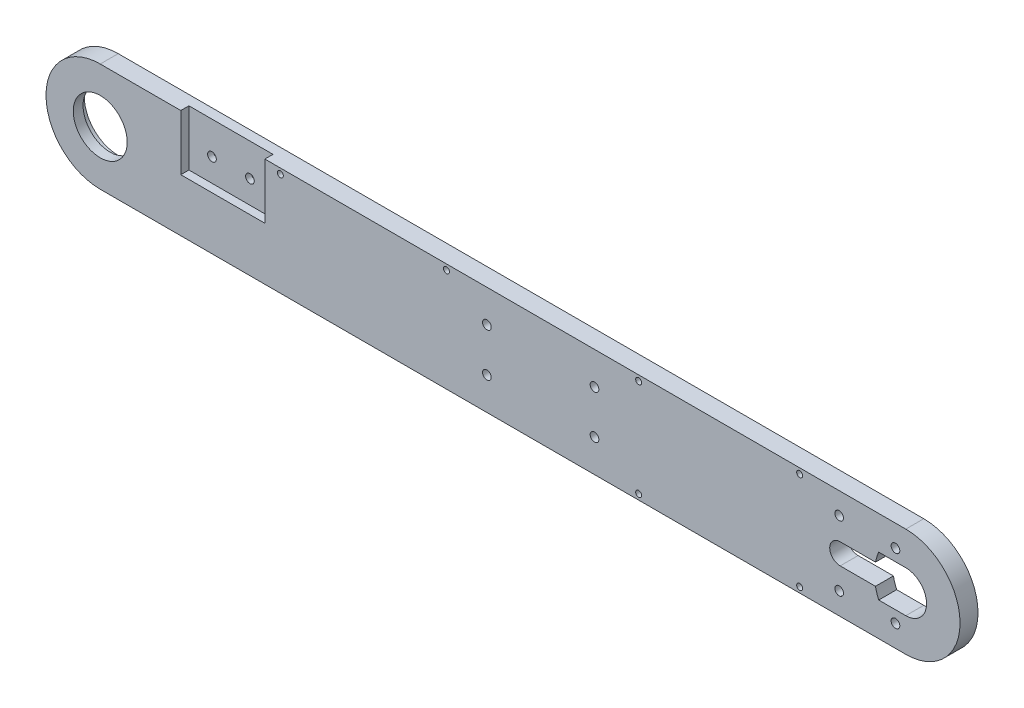
from build123d import *

# Parameters (mm, degrees)
BOSS_EXTRUDE1_DEPTH = 6.62
CUT_EXTRUDE1_REACH  = 8.62
CUT_EXTRUDE2_REACH  = 8.62
SKETCH3_R           = 1.6
SKETCH4_R           = 2.75
CUT_EXTRUDE3_DEPTH  = 3.2
SKETCH6_R           = 9.95
CUT_EXTRUDE4_DEPTH  = 10
SKETCH7_R           = 12.5
CUT_EXTRUDE5_DEPTH  = 3
CUT_EXTRUDE9_REACH  = 8.62
SKETCH10_R          = 1.600000003
SKETCH11_R          = 2.750000001
CUT_EXTRUDE10_DEPTH = 3
SKETCH12_W          = 31
SKETCH12_H          = 20.5
CUT_EXTRUDE11_DEPTH = 3
CUT_EXTRUDE12_REACH = 8.62
SKETCH13_R          = 1.6
SKETCH14_R          = 2.75
CUT_EXTRUDE13_DEPTH = 1.5
CUT_EXTRUDE14_REACH = 8.62
SKETCH15_R          = 1.1


with BuildPart() as part:
    # Sketch1 → Boss-Extrude1 (new body)
    with BuildSketch(Plane.XY):
        with BuildLine():
            Line((-53.15, -20.367507575), (-350.15, -20.367507575))
            ThreePointArc((-350.15, -20.367507575), (-370.15, -0.367507575), (-350.15, 19.632492425))
            Line((-350.15, 19.632492425), (-53.15, 19.632492425))
            ThreePointArc((-53.15, 19.632492425), (-33.15, -0.367507575), (-53.15, -20.367507575))
        make_face()
    extrude(amount=BOSS_EXTRUDE1_DEPTH)

    # Sketch2 → Cut-Extrude1 (cut, up to next)
    with BuildSketch(Plane(origin=(0, 0, 0), x_dir=(-1, 0, 0), z_dir=(0, 0, -1)), mode=Mode.PRIVATE) as cut_extrude1_sk1:
        with BuildLine():
            Line((53.15, 7.282492425), (63.133045479, 7.282492425))
            ThreePointArc((63.133045479, 7.282492425), (63.830991164, 5.41363036), (64.33147081, 3.482492425))
            Line((64.33147081, 3.482492425), (77.35, 3.482492425))
            ThreePointArc((77.35, 3.482492425), (81.2, -0.367507575), (77.35, -4.217507575))
            Line((77.35, -4.217507575), (64.33147081, -4.217507575))
            ThreePointArc((64.33147081, -4.217507575), (63.830991164, -6.14864551), (63.133045479, -8.017507575))
            Line((63.133045479, -8.017507575), (53.15, -8.017507575))
            ThreePointArc((53.15, -8.017507575), (45.5, -0.367507575), (53.15, 7.282492425))
        make_face()
    cut_extrude1_tool1 = extrude(cut_extrude1_sk1.sketch, amount=-CUT_EXTRUDE1_REACH, mode=Mode.PRIVATE) & part.part
    add(cut_extrude1_tool1.solids().sort_by_distance((-60.965388, -0.367508, 0))[0], mode=Mode.SUBTRACT)

    # Sketch3 → Cut-Extrude2 (cut, up to next)
    with BuildSketch(Plane(origin=(0, 0, 0), x_dir=(-1, 0, 0), z_dir=(0, 0, -1)), mode=Mode.PRIVATE) as cut_extrude2_sk1:
        with Locations((77.715530374, -12.367507575)):
            Circle(SKETCH3_R)
    cut_extrude2_tool1 = extrude(cut_extrude2_sk1.sketch, amount=-CUT_EXTRUDE2_REACH, mode=Mode.PRIVATE) & part.part
    add(cut_extrude2_tool1.solids().sort_by_distance((-77.71553, -12.367508, 0))[0], mode=Mode.SUBTRACT)
    # Sketch3 → Cut-Extrude2 (cut, up to next)
    with BuildSketch(Plane(origin=(0, 0, 0), x_dir=(-1, 0, 0), z_dir=(0, 0, -1)), mode=Mode.PRIVATE) as cut_extrude2_sk2:
        with Locations((77.715530374, 11.632492425)):
            Circle(SKETCH3_R)
    cut_extrude2_tool2 = extrude(cut_extrude2_sk2.sketch, amount=-CUT_EXTRUDE2_REACH, mode=Mode.PRIVATE) & part.part
    add(cut_extrude2_tool2.solids().sort_by_distance((-77.71553, 11.632492, 0))[0], mode=Mode.SUBTRACT)
    # Sketch3 → Cut-Extrude2 (cut, up to next)
    with BuildSketch(Plane(origin=(0, 0, 0), x_dir=(-1, 0, 0), z_dir=(0, 0, -1)), mode=Mode.PRIVATE) as cut_extrude2_sk3:
        with Locations((56.965530374, 11.632492425)):
            Circle(SKETCH3_R)
    cut_extrude2_tool3 = extrude(cut_extrude2_sk3.sketch, amount=-CUT_EXTRUDE2_REACH, mode=Mode.PRIVATE) & part.part
    add(cut_extrude2_tool3.solids().sort_by_distance((-56.96553, 11.632492, 0))[0], mode=Mode.SUBTRACT)
    # Sketch3 → Cut-Extrude2 (cut, up to next)
    with BuildSketch(Plane(origin=(0, 0, 0), x_dir=(-1, 0, 0), z_dir=(0, 0, -1)), mode=Mode.PRIVATE) as cut_extrude2_sk4:
        with Locations((56.965530374, -12.367507575)):
            Circle(SKETCH3_R)
    cut_extrude2_tool4 = extrude(cut_extrude2_sk4.sketch, amount=-CUT_EXTRUDE2_REACH, mode=Mode.PRIVATE) & part.part
    add(cut_extrude2_tool4.solids().sort_by_distance((-56.96553, -12.367508, 0))[0], mode=Mode.SUBTRACT)

    # Sketch4 → Cut-Extrude3 (cut)
    with BuildSketch(Plane(origin=(0, 0, 0), x_dir=(-1, 0, 0), z_dir=(0, 0, -1))):
        with Locations((56.965530374, 11.632492425)):
            Circle(SKETCH4_R)
        with Locations((77.715530374, 11.632492425)):
            Circle(SKETCH4_R)
        with Locations((77.715530374, -12.367507575)):
            Circle(SKETCH4_R)
        with Locations((56.965530374, -12.367507575)):
            Circle(SKETCH4_R)
    extrude(amount=-CUT_EXTRUDE3_DEPTH, mode=Mode.SUBTRACT)

    # Sketch6 → Cut-Extrude4 (cut)
    with BuildSketch(Plane.XY.offset(6.62)):
        with Locations((-350.15, -0.367507575)):
            Circle(SKETCH6_R)
    extrude(amount=-CUT_EXTRUDE4_DEPTH, mode=Mode.SUBTRACT)

    # Sketch7 → Cut-Extrude5 (cut)
    with BuildSketch(Plane(origin=(0, 0, 0), x_dir=(-1, 0, 0), z_dir=(0, 0, -1))):
        with Locations((350.15, -0.367507575)):
            Circle(SKETCH7_R)
    extrude(amount=-CUT_EXTRUDE5_DEPTH, mode=Mode.SUBTRACT)

    # Sketch10 → Cut-Extrude9 (cut, up to next)
    with BuildSketch(Plane.XY.offset(6.62), mode=Mode.PRIVATE) as cut_extrude9_sk1:
        with Locations((-207.590530375, -8.367507581)):
            Circle(SKETCH10_R)
    cut_extrude9_tool1 = extrude(cut_extrude9_sk1.sketch, amount=-CUT_EXTRUDE9_REACH, mode=Mode.PRIVATE) & part.part
    add(cut_extrude9_tool1.solids().sort_by_distance((-207.59053, -8.367508, 6.62))[0], mode=Mode.SUBTRACT)
    # Sketch10 → Cut-Extrude9 (cut, up to next)
    with BuildSketch(Plane.XY.offset(6.62), mode=Mode.PRIVATE) as cut_extrude9_sk2:
        with Locations((-207.590530375, 7.632492419)):
            Circle(SKETCH10_R)
    cut_extrude9_tool2 = extrude(cut_extrude9_sk2.sketch, amount=-CUT_EXTRUDE9_REACH, mode=Mode.PRIVATE) & part.part
    add(cut_extrude9_tool2.solids().sort_by_distance((-207.59053, 7.632492, 6.62))[0], mode=Mode.SUBTRACT)
    # Sketch10 → Cut-Extrude9 (cut, up to next)
    with BuildSketch(Plane.XY.offset(6.62), mode=Mode.PRIVATE) as cut_extrude9_sk3:
        with Locations((-167.917908126, -8.367507581)):
            Circle(SKETCH10_R)
    cut_extrude9_tool3 = extrude(cut_extrude9_sk3.sketch, amount=-CUT_EXTRUDE9_REACH, mode=Mode.PRIVATE) & part.part
    add(cut_extrude9_tool3.solids().sort_by_distance((-167.917908, -8.367508, 6.62))[0], mode=Mode.SUBTRACT)
    # Sketch10 → Cut-Extrude9 (cut, up to next)
    with BuildSketch(Plane.XY.offset(6.62), mode=Mode.PRIVATE) as cut_extrude9_sk4:
        with Locations((-167.917908126, 7.632492419)):
            Circle(SKETCH10_R)
    cut_extrude9_tool4 = extrude(cut_extrude9_sk4.sketch, amount=-CUT_EXTRUDE9_REACH, mode=Mode.PRIVATE) & part.part
    add(cut_extrude9_tool4.solids().sort_by_distance((-167.917908, 7.632492, 6.62))[0], mode=Mode.SUBTRACT)

    # Sketch11 → Cut-Extrude10 (cut)
    with BuildSketch(Plane(origin=(0, 0, 0), x_dir=(-1, 0, 0), z_dir=(0, 0, -1))):
        with Locations((207.590530375, 7.632492419)):
            Circle(SKETCH11_R)
        with Locations((207.590530375, -8.367507581)):
            Circle(SKETCH11_R)
        with Locations((167.917908126, 7.632492419)):
            Circle(SKETCH11_R)
        with Locations((167.917908126, -8.367507581)):
            Circle(SKETCH11_R)
    extrude(amount=-CUT_EXTRUDE10_DEPTH, mode=Mode.SUBTRACT)

    # Sketch12 → Cut-Extrude11 (cut)
    with BuildSketch(Plane.XY.offset(6.62)):
        with Locations((-304.957095584, 9.382492425)):
            Rectangle(SKETCH12_W, SKETCH12_H)
    extrude(amount=-CUT_EXTRUDE11_DEPTH, mode=Mode.SUBTRACT)

    # Sketch13 → Cut-Extrude12 (cut, up to next)
    with BuildSketch(Plane.XY.offset(6.62), mode=Mode.PRIVATE) as cut_extrude12_sk1:
        with Locations((-311.957095584, 7.632492425)):
            Circle(SKETCH13_R)
    cut_extrude12_tool1 = extrude(cut_extrude12_sk1.sketch, amount=-CUT_EXTRUDE12_REACH, mode=Mode.PRIVATE) & part.part
    add(cut_extrude12_tool1.solids().sort_by_distance((-311.957096, 7.632492, 6.62))[0], mode=Mode.SUBTRACT)
    # Sketch13 → Cut-Extrude12 (cut, up to next)
    with BuildSketch(Plane.XY.offset(6.62), mode=Mode.PRIVATE) as cut_extrude12_sk2:
        with Locations((-297.957095584, 7.632492425)):
            Circle(SKETCH13_R)
    cut_extrude12_tool2 = extrude(cut_extrude12_sk2.sketch, amount=-CUT_EXTRUDE12_REACH, mode=Mode.PRIVATE) & part.part
    add(cut_extrude12_tool2.solids().sort_by_distance((-297.957096, 7.632492, 6.62))[0], mode=Mode.SUBTRACT)

    # Sketch14 → Cut-Extrude13 (cut)
    with BuildSketch(Plane(origin=(0, 0, 0), x_dir=(-1, 0, 0), z_dir=(0, 0, -1))):
        with Locations((311.957095584, 7.632492425)):
            Circle(SKETCH14_R)
        with Locations((297.957095584, 7.632492425)):
            Circle(SKETCH14_R)
    extrude(amount=-CUT_EXTRUDE13_DEPTH, mode=Mode.SUBTRACT)

    # Sketch15 → Cut-Extrude14 (cut, up to next)
    with BuildSketch(Plane.XY.offset(6.62), mode=Mode.PRIVATE) as cut_extrude14_sk1:
        with Locations((-151.644507933, -18.367507575)):
            Circle(SKETCH15_R)
    cut_extrude14_tool1 = extrude(cut_extrude14_sk1.sketch, amount=-CUT_EXTRUDE14_REACH, mode=Mode.PRIVATE) & part.part
    add(cut_extrude14_tool1.solids().sort_by_distance((-151.644508, -18.367508, 6.62))[0], mode=Mode.SUBTRACT)
    # Sketch15 → Cut-Extrude14 (cut, up to next)
    with BuildSketch(Plane.XY.offset(6.62), mode=Mode.PRIVATE) as cut_extrude14_sk2:
        with Locations((-92.280362099, -18.367507575)):
            Circle(SKETCH15_R)
    cut_extrude14_tool2 = extrude(cut_extrude14_sk2.sketch, amount=-CUT_EXTRUDE14_REACH, mode=Mode.PRIVATE) & part.part
    add(cut_extrude14_tool2.solids().sort_by_distance((-92.280362, -18.367508, 6.62))[0], mode=Mode.SUBTRACT)
    # Sketch15 → Cut-Extrude14 (cut, up to next)
    with BuildSketch(Plane.XY.offset(6.62), mode=Mode.PRIVATE) as cut_extrude14_sk3:
        with Locations((-151.644507933, 17.632492425)):
            Circle(SKETCH15_R)
    cut_extrude14_tool3 = extrude(cut_extrude14_sk3.sketch, amount=-CUT_EXTRUDE14_REACH, mode=Mode.PRIVATE) & part.part
    add(cut_extrude14_tool3.solids().sort_by_distance((-151.644508, 17.632492, 6.62))[0], mode=Mode.SUBTRACT)
    # Sketch15 → Cut-Extrude14 (cut, up to next)
    with BuildSketch(Plane.XY.offset(6.62), mode=Mode.PRIVATE) as cut_extrude14_sk4:
        with Locations((-92.280362099, 17.632492425)):
            Circle(SKETCH15_R)
    cut_extrude14_tool4 = extrude(cut_extrude14_sk4.sketch, amount=-CUT_EXTRUDE14_REACH, mode=Mode.PRIVATE) & part.part
    add(cut_extrude14_tool4.solids().sort_by_distance((-92.280362, 17.632492, 6.62))[0], mode=Mode.SUBTRACT)
    # Sketch15 → Cut-Extrude14 (cut, up to next)
    with BuildSketch(Plane.XY.offset(6.62), mode=Mode.PRIVATE) as cut_extrude14_sk5:
        with Locations((-222.491552839, 17.632492425)):
            Circle(SKETCH15_R)
    cut_extrude14_tool5 = extrude(cut_extrude14_sk5.sketch, amount=-CUT_EXTRUDE14_REACH, mode=Mode.PRIVATE) & part.part
    add(cut_extrude14_tool5.solids().sort_by_distance((-222.491553, 17.632492, 6.62))[0], mode=Mode.SUBTRACT)
    # Sketch15 → Cut-Extrude14 (cut, up to next)
    with BuildSketch(Plane.XY.offset(6.62), mode=Mode.PRIVATE) as cut_extrude14_sk6:
        with Locations((-283.750452743, 17.632492425)):
            Circle(SKETCH15_R)
    cut_extrude14_tool6 = extrude(cut_extrude14_sk6.sketch, amount=-CUT_EXTRUDE14_REACH, mode=Mode.PRIVATE) & part.part
    add(cut_extrude14_tool6.solids().sort_by_distance((-283.750453, 17.632492, 6.62))[0], mode=Mode.SUBTRACT)


solid = part.part
